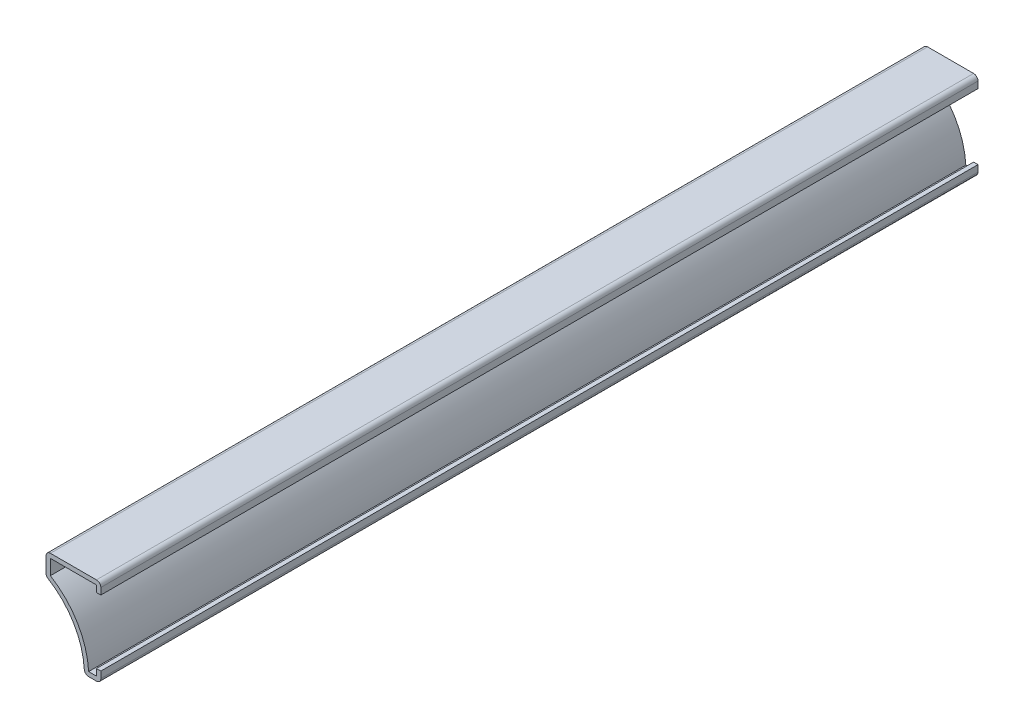
from build123d import *

# Parameters (mm, degrees)
EXTRUDE_THIN1_DEPTH = 254
FILLET1_R           = 1.27


with BuildPart() as part:
    # Sketch1 → Extrude-Thin1 (new body)
    with BuildSketch(Plane.XY):
        with BuildLine():
            Line((0, 0), (0, -3.175))
            Line((0, -3.175), (-4.7625, -3.175))
            ThreePointArc((-4.7625, -3.175), (-7.743674429, 7.852127417), (-15.875, 15.875))
            Line((-15.875, 15.875), (-15.875, 22.225))
            Line((-15.875, 22.225), (0, 22.225))
            Line((0, 22.225), (0, 19.05))
            Line((0, 19.05), (-1.27, 19.05))
            Line((-1.27, 19.05), (-1.27, 20.955))
            Line((-1.27, 20.955), (-14.605, 20.955))
            Line((-14.605, 20.955), (-14.605, 16.601962608))
            ThreePointArc((-14.605, 16.601962608), (-6.779670812, 8.71710723), (-3.527354833, -1.905))
            Line((-3.527354833, -1.905), (-1.27, -1.905))
            Line((-1.27, -1.905), (-1.27, 0))
            Line((-1.27, 0), (0, 0))
        make_face()
    extrude(amount=-EXTRUDE_THIN1_DEPTH)

    # Fillet1
    fillet1_edges = [part.edges().sort_by_distance(p)[0] for p in [
        (0, -3.175, -127),
        (-4.7625, -3.175, -127),
        (-15.875, 15.875, -127),
        (-15.875, 22.225, -127),
        (0, 22.225, -127),
    ]]
    fillet(fillet1_edges, radius=FILLET1_R)


solid = part.part
